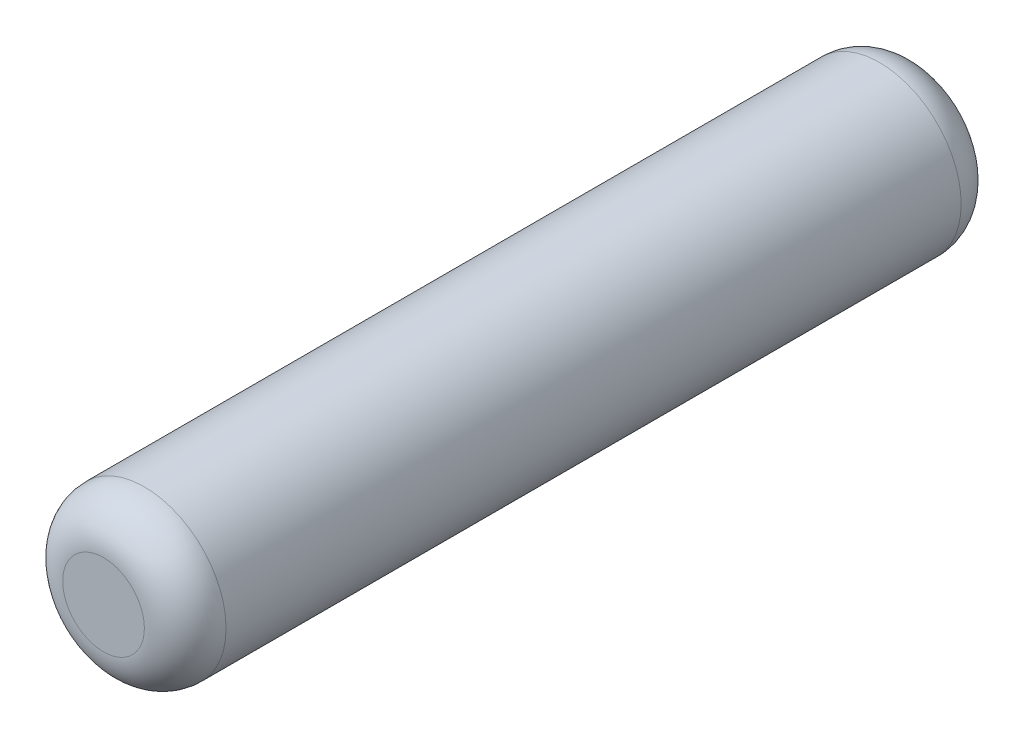
from build123d import *

# Parameters (mm, degrees)
SKETCH_1_R      = 2
EXTRUDE_1_DEPTH = 10
FILLET_1_R      = 1


with BuildPart() as part:
    # 스케치1 → 보스-돌출1 (new body, symmetric)
    with BuildSketch(Plane.XY):
        Circle(SKETCH_1_R)
    extrude(amount=EXTRUDE_1_DEPTH, both=True)

    # 필렛1
    fillet_1_edges = [part.edges().sort_by_distance(p)[0] for p in [
        (-2, 0, -10),
        (-2, 0, 10),
    ]]
    fillet(fillet_1_edges, radius=FILLET_1_R)


solid = part.part
